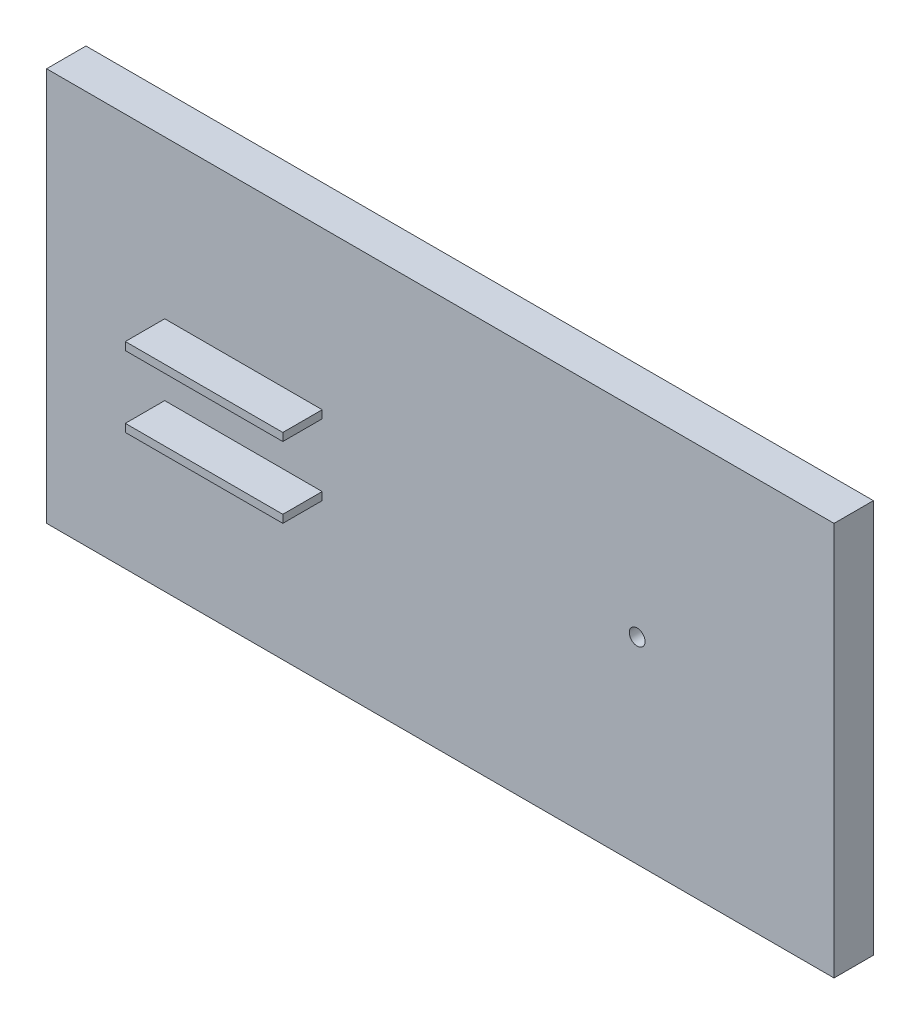
from build123d import *

# Parameters (mm, degrees)
SKETCH1_W           = 40
SKETCH1_H           = 2
BOSS_EXTRUDE2_DEPTH = 10
SKETCH1_4_W         = 40
SKETCH1_4_H         = 2
BOSS_EXTRUDE3_DEPTH = 20


with BuildPart() as part:
    # Sketch1 → Boss-Extrude2 (new body)
    with BuildSketch(Plane.XY):
        Polygon((-100, -50), (50, -50), (100, -50), (100, 50), (-100, 50), align=None)
        Polygon((-70, -10), (-70, -8), (-30, -8), (-30, -10), (-40, -10), (-60, -10), align=None, mode=Mode.SUBTRACT)
        with Locations((-50, 9)):
            Rectangle(SKETCH1_W, SKETCH1_H, mode=Mode.SUBTRACT)
        with BuildLine():
            ThreePointArc((52, 0), (51.414213562, -1.414213562), (50, -2))
            ThreePointArc((50, -2), (48.585786438, 1.414213562), (52, 0))
        make_face(mode=Mode.SUBTRACT)
    extrude(amount=BOSS_EXTRUDE2_DEPTH)

    # Sketch1_4 → Boss-Extrude3 (add)
    with BuildSketch(Plane.XY):
        with Locations((-50, 9)):
            Rectangle(SKETCH1_4_W, SKETCH1_4_H)
        with Locations((-50, -9)):
            Rectangle(SKETCH1_4_W, SKETCH1_4_H)
    extrude(amount=BOSS_EXTRUDE3_DEPTH)


solid = part.part
